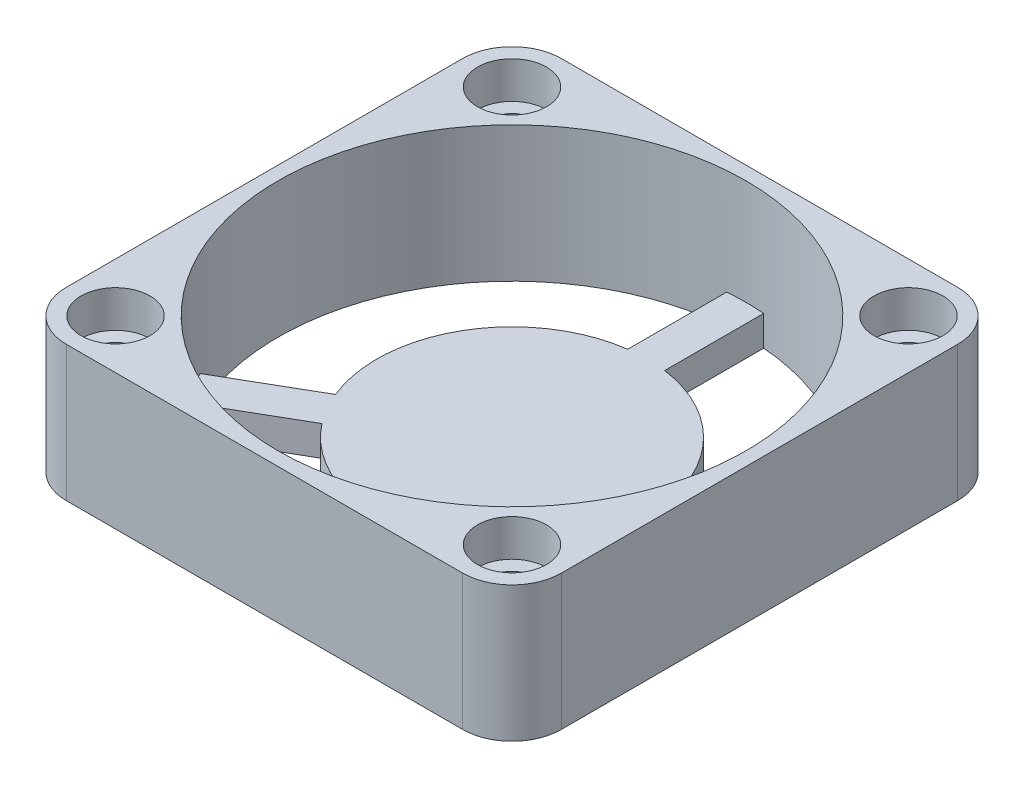
from build123d import *

# Parameters (mm, degrees)
RESSALTO_EXTRUS_O1_DEPTH = 5.5
ESBO_O2_R                = 19
CORTE_EXTRUS_O1_DEPTH    = 8.55
CORTE_EXTRUS_O2_DEPTH    = 3.45
ESBO_O4_R                = 1.6
CORTE_EXTRUS_O3_DEPTH    = 12
ESBO_O5_R                = 2.8
CORTE_EXTRUS_O4_DEPTH    = 3


with BuildPart() as part:
    # Esboço1 → Ressalto-extrusão1 (new body, symmetric)
    with BuildSketch(Plane(origin=(0, 0, 0), x_dir=(1, 0, 0), z_dir=(0, 1, 0))):
        with BuildLine():
            Line((-16.1, -20.1), (16.1, -20.1))
            ThreePointArc((16.1, -20.1), (18.928427125, -18.928427125), (20.1, -16.1))
            Line((20.1, -16.1), (20.1, 16.1))
            ThreePointArc((20.1, 16.1), (18.928427125, 18.928427125), (16.1, 20.1))
            Line((16.1, 20.1), (-16.1, 20.1))
            ThreePointArc((-16.1, 20.1), (-18.928427125, 18.928427125), (-20.1, 16.1))
            Line((-20.1, 16.1), (-20.1, -16.1))
            ThreePointArc((-20.1, -16.1), (-18.928427125, -18.928427125), (-16.1, -20.1))
        make_face()
    extrude(amount=RESSALTO_EXTRUS_O1_DEPTH, both=True)

    # Esboço2 → Corte-extrusão1 (cut)
    with BuildSketch(Plane(origin=(0, 5.5, 0), x_dir=(1, 0, 0), z_dir=(0, 1, 0))):
        Circle(ESBO_O2_R)
    extrude(amount=-CORTE_EXTRUS_O1_DEPTH, mode=Mode.SUBTRACT)

    # Esboço3 → Corte-extrusão2 (cut, through all)
    with BuildSketch(Plane(origin=(0, -3.05, 0), x_dir=(1, 0, 0), z_dir=(0, 1, 0))):
        with BuildLine():
            Line((1.5, 10.897247359), (1.5, 18.940696925))
            ThreePointArc((1.5, 18.940696925), (16.454482672, 9.5), (17.153124702, -8.171310357))
            Line((17.153124702, -8.171310357), (10.187293044, -4.149585574))
            ThreePointArc((10.187293044, -4.149585574), (9.526279442, 5.5), (1.5, 10.897247359))
        make_face()
        with BuildLine():
            Line((-1.5, 10.897247359), (-1.5, 18.940696925))
            ThreePointArc((-1.5, 18.940696925), (-16.454482672, 9.5), (-17.153124702, -8.171310357))
            Line((-17.153124702, -8.171310357), (-10.187293044, -4.149585574))
            ThreePointArc((-10.187293044, -4.149585574), (-9.526279442, 5.5), (-1.5, 10.897247359))
        make_face()
        with BuildLine():
            Line((8.687293044, -6.747661785), (15.653124702, -10.769386568))
            ThreePointArc((15.653124702, -10.769386568), (0, -19), (-15.653124702, -10.769386568))
            Line((-15.653124702, -10.769386568), (-8.687293044, -6.747661785))
            ThreePointArc((-8.687293044, -6.747661785), (0, -11), (8.687293044, -6.747661785))
        make_face()
    extrude(amount=-CORTE_EXTRUS_O2_DEPTH, mode=Mode.SUBTRACT)

    # Esboço4 → Corte-extrusão3 (cut, through all)
    with BuildSketch(Plane.XZ.offset(5.5)):
        with Locations((-16.1, 16.1)):
            Circle(ESBO_O4_R)
        with Locations((16.1, 16.1)):
            Circle(ESBO_O4_R)
        with Locations((16.1, -16.1)):
            Circle(ESBO_O4_R)
        with Locations((-16.1, -16.1)):
            Circle(ESBO_O4_R)
    extrude(amount=-CORTE_EXTRUS_O3_DEPTH, mode=Mode.SUBTRACT)

    # Esboço5 → Corte-extrusão4 (cut)
    with BuildSketch(Plane(origin=(0, 5.5, 0), x_dir=(1, 0, 0), z_dir=(0, 1, 0))):
        with Locations((-16.1, 16.1)):
            Circle(ESBO_O5_R)
        with Locations((-16.1, -16.1)):
            Circle(ESBO_O5_R)
        with Locations((16.1, -16.1)):
            Circle(ESBO_O5_R)
        with Locations((16.1, 16.1)):
            Circle(ESBO_O5_R)
    extrude(amount=-CORTE_EXTRUS_O4_DEPTH, mode=Mode.SUBTRACT)


solid = part.part
